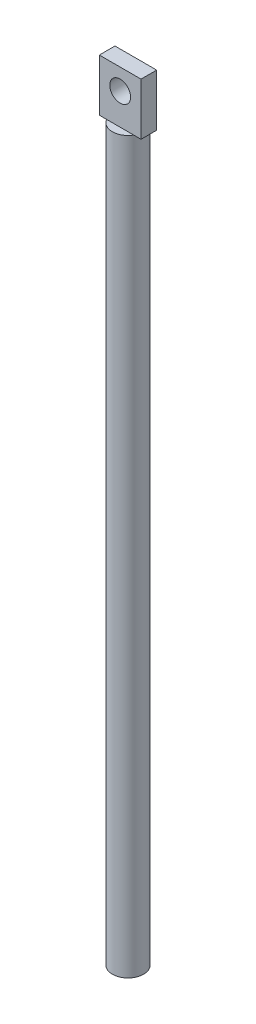
from build123d import *

# Parameters (mm, degrees)
SKETCH1_R           = 1.5
BOSS_EXTRUDE1_DEPTH = 70
SKETCH2_W           = 4
SKETCH2_H           = 1.5
BOSS_EXTRUDE2_DEPTH = 5
SKETCH3_R           = 1
CUT_EXTRUDE1_DEPTH  = 3.25


with BuildPart() as part:
    # Sketch1 → Boss-Extrude1 (new body)
    with BuildSketch(Plane(origin=(0, 0, 0), x_dir=(1, 0, 0), z_dir=(0, 1, 0))):
        Circle(SKETCH1_R)
    extrude(amount=BOSS_EXTRUDE1_DEPTH)

    # Sketch2 → Boss-Extrude2 (add)
    with BuildSketch(Plane(origin=(0, 70, 0), x_dir=(1, 0, 0), z_dir=(0, 1, 0))):
        Rectangle(SKETCH2_W, SKETCH2_H)
    extrude(amount=BOSS_EXTRUDE2_DEPTH)

    # Sketch3 → Cut-Extrude1 (cut, through all)
    with BuildSketch(Plane(origin=(0, 0, -0.75), x_dir=(-1, 0, 0), z_dir=(0, 0, -1))):
        with Locations((0, 73)):
            Circle(SKETCH3_R)
    extrude(amount=-CUT_EXTRUDE1_DEPTH, mode=Mode.SUBTRACT)


solid = part.part
